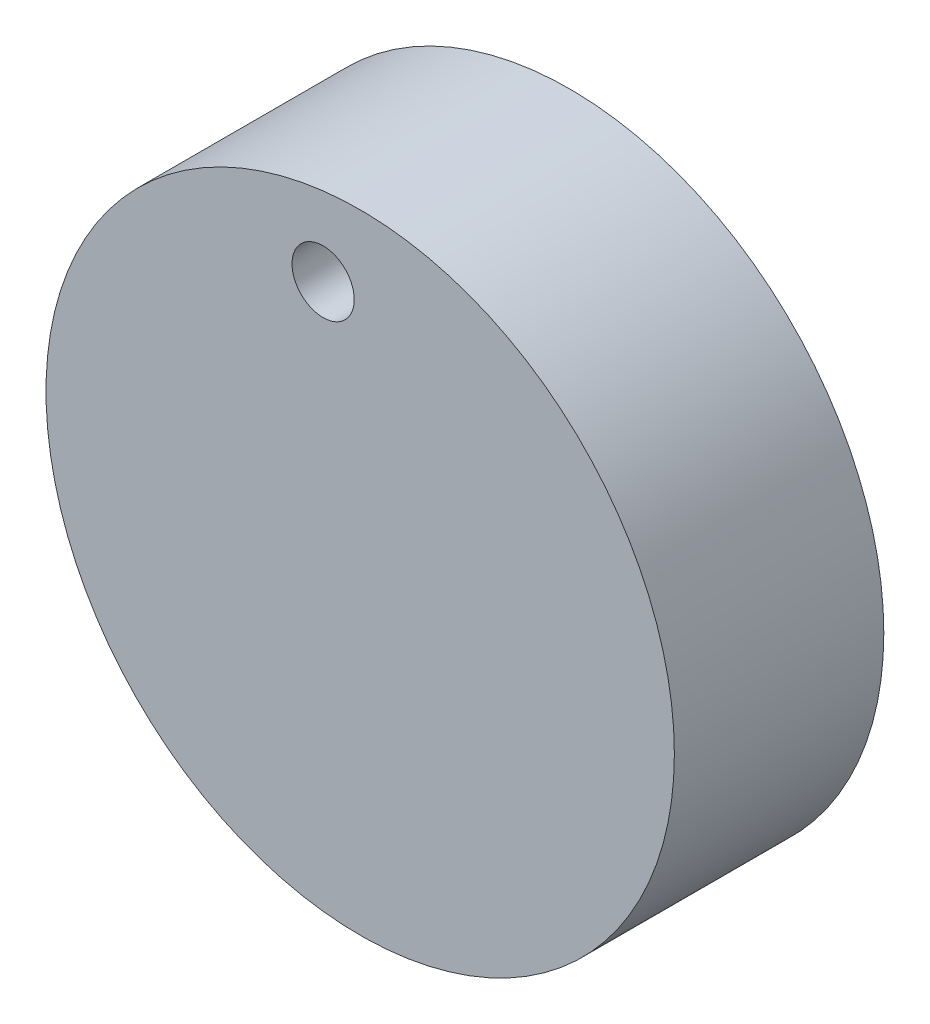
from build123d import *

# Parameters (mm, degrees)
SKETCH1_R      = 9
EXTRUDE1_DEPTH = 6
SKETCH2_R      = 0.891442854
EXTRUDE2_DEPTH = 7


with BuildPart() as part:
    # Sketch1 → Extrude1 (new body)
    with BuildSketch(Plane.XY):
        Circle(SKETCH1_R)
    extrude(amount=EXTRUDE1_DEPTH)

    # Sketch2 → Extrude2 (cut, through all)
    with BuildSketch(Plane.XY.offset(6)):
        with Locations((-1.061845077, 6.683918066)):
            Circle(SKETCH2_R)
    extrude(amount=-EXTRUDE2_DEPTH, mode=Mode.SUBTRACT)


solid = part.part
